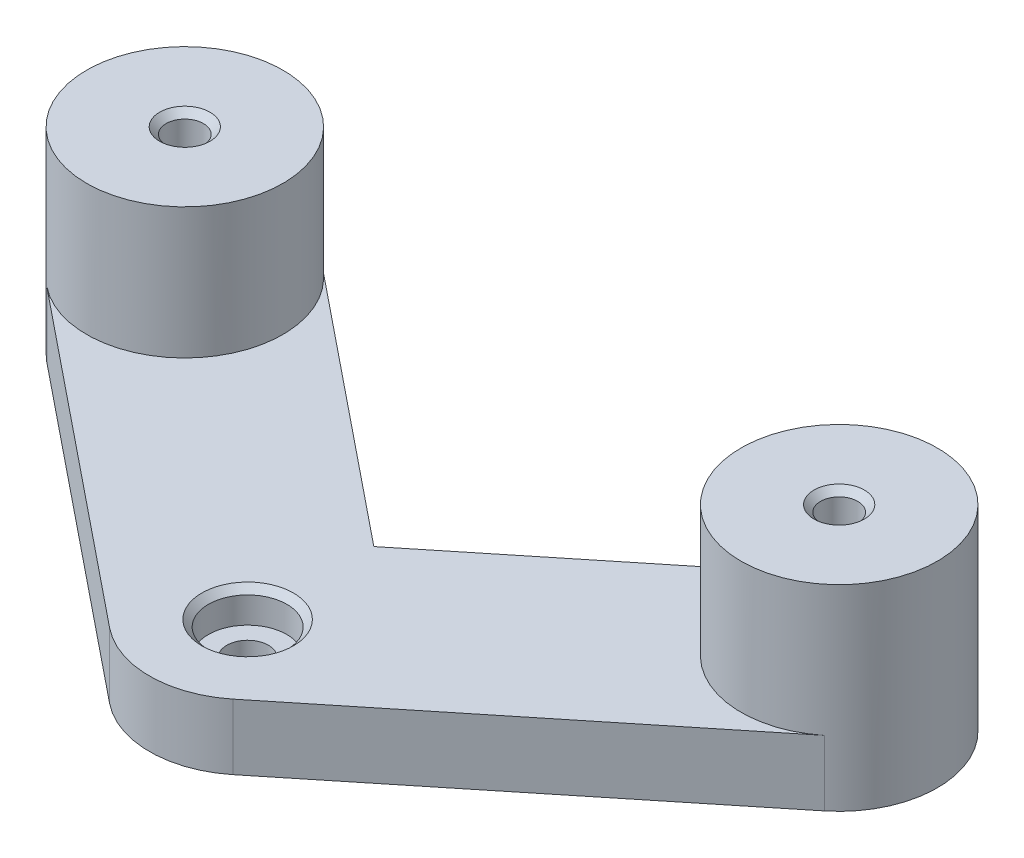
from build123d import *

# Parameters (mm, degrees)
SKETCH10_R          = 3.175
BOSS_EXTRUDE4_DEPTH = 10
SKETCH11_R          = 15
BOSS_EXTRUDE5_DEPTH = 20
SKETCH12_R          = 2.85
CUT_EXTRUDE4_DEPTH  = 37
SKETCH13_R          = 6
CUT_EXTRUDE5_DEPTH  = 5
CHAMFER2_SIZE       = 1


with BuildPart() as part:
    # Sketch10 → Boss-Extrude4 (new body)
    with BuildSketch(Plane(origin=(0, 0, 0), x_dir=(1, 0, 0), z_dir=(0, 1, 0))):
        with BuildLine():
            Line((-40.573129599, -74.934887896), (0, -107.71591519))
            Line((0, -107.71591519), (40.573129599, -74.934887896))
            ThreePointArc((40.573129599, -74.934887896), (61.667652482, -77.175669978), (59.426870401, -98.270192861))
            Line((59.426870401, -98.270192861), (9.426870401, -138.667652482))
            ThreePointArc((9.426870401, -138.667652482), (0, -142), (-9.426870401, -138.667652482))
            Line((-9.426870401, -138.667652482), (-59.426870401, -98.270192861))
            ThreePointArc((-59.426870401, -98.270192861), (-61.667652482, -77.175669978), (-40.573129599, -74.934887896))
        make_face()
        with Locations((0, -127)):
            Circle(SKETCH10_R, mode=Mode.SUBTRACT)
    extrude(amount=BOSS_EXTRUDE4_DEPTH)

    # Sketch11 → Boss-Extrude5 (add)
    with BuildSketch(Plane(origin=(0, 10, 0), x_dir=(1, 0, 0), z_dir=(0, 1, 0))):
        with Locations((-50, -86.602540378)):
            Circle(SKETCH11_R)
        with Locations((50, -86.602540378)):
            Circle(SKETCH11_R)
    extrude(amount=BOSS_EXTRUDE5_DEPTH)

    # Sketch12 → Cut-Extrude4 (cut)
    with BuildSketch(Plane(origin=(0, 30, 0), x_dir=(1, 0, 0), z_dir=(0, 1, 0))):
        with Locations((-50, -86.602540378)):
            Circle(SKETCH12_R)
        with Locations((50, -86.602540378)):
            Circle(SKETCH12_R)
    extrude(amount=-CUT_EXTRUDE4_DEPTH, mode=Mode.SUBTRACT)

    # Sketch13 → Cut-Extrude5 (cut)
    with BuildSketch(Plane(origin=(0, 10, 0), x_dir=(1, 0, 0), z_dir=(0, 1, 0))):
        with Locations((0, -127)):
            Circle(SKETCH13_R)
    extrude(amount=-CUT_EXTRUDE5_DEPTH, mode=Mode.SUBTRACT)

    # Chamfer2
    chamfer2_edges = [part.edges().sort_by_distance(p)[0] for p in [
        (-52.85, 30, 86.602540378),
        (47.15, 30, 86.602540378),
        (-6, 10, 127),
    ]]
    chamfer(chamfer2_edges, length=CHAMFER2_SIZE)


solid = part.part
